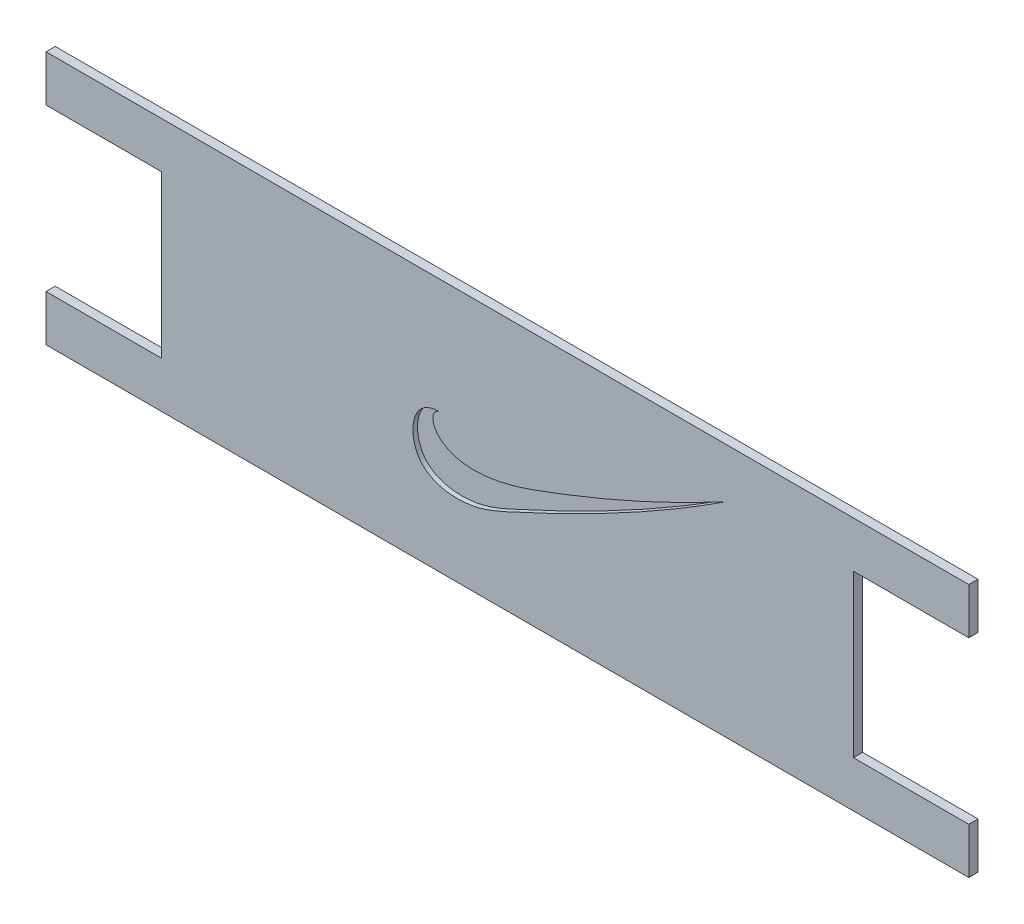
from build123d import *

# Parameters (mm, degrees)
BOSS_EXTRUDE1_DEPTH = 2
CUT_EXTRUDE1_DEPTH  = 1
SCALE1_SCALE        = 0.5


with BuildPart() as part:
    # Sketch1 → Boss-Extrude1 (new body)
    with BuildSketch(Plane.XY):
        Polygon((-48.310810811, 14.243974201), (151.689189189, 14.243974201), (151.689189189, 4.243974201), (126.689189189, 4.243974201), (126.689189189, -30.756025799), (151.689189189, -30.756025799), (151.689189189, -40.756025799), (-48.310810811, -40.756025799), (-48.310810811, -30.756025799), (-23.310810811, -30.756025799), (-23.310810811, 4.243974201), (-48.310810811, 4.243974201), align=None)
    extrude(amount=BOSS_EXTRUDE1_DEPTH)

    # Sketch3 → Cut-Extrude1 (cut)
    with BuildSketch(Plane.XY.offset(2)):
        with BuildLine():
            add(Edge.make_bspline(
                [(37.189484824, -10.718294686), (33.474166953, -10.624199422), (35.300627772, -23.216467907), (74.220048032, -9.046257892), (87.664897587, -2.594986042), (98.853365994, 3.337442933)],
                knots=[0, 0, 0, 0, 0.51776511, 0.592619661, 1, 1, 1, 1], degree=3))
            add(Edge.make_bspline(
                [(37.189484824, -10.718294686), (30.815944463, -10.332745105), (29.156875012, -24.169852988), (43.250186434, -25.85327449), (65.190161886, -16.178918043), (83.996504619, -6.384768657), (98.853365994, 3.337442933)],
                knots=[0, 0, 0, 0, 0.163170519, 0.29176393, 0.388322168, 1, 1, 1, 1], degree=3))
        make_face()
    extrude(amount=-CUT_EXTRUDE1_DEPTH, mode=Mode.SUBTRACT)


with BuildPart() as part_1:
    # Scale1: scaled about (51.685288163, -13.204114524, 0.992436244)
    add(part.part.scale(SCALE1_SCALE).moved(Location((25.842644082, -6.602057262, 0.496218122))))


solid = part_1.part
